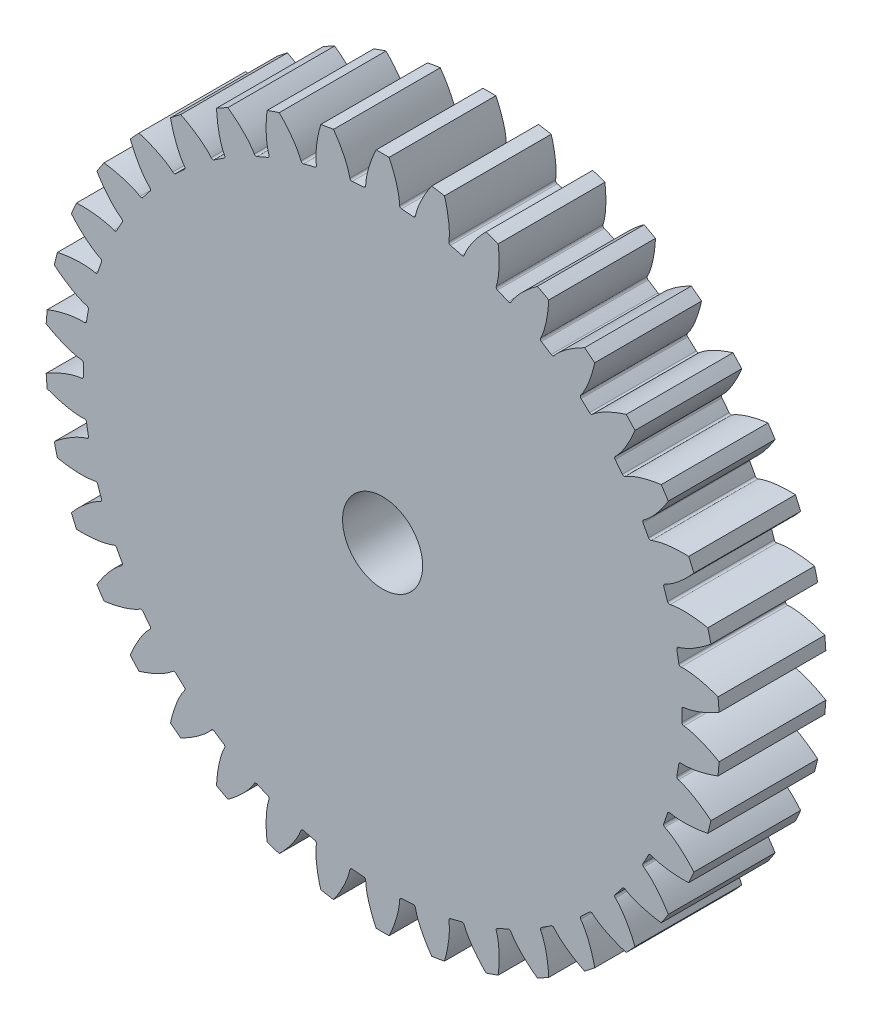
from build123d import *

# Parameters (mm, degrees)
SKETCH4_R                                  = 12.63
ADDENDUM_EXTRUDED_DEPTH                    = 2
F_1_2_TOOTH_CUT_DEPTH                      = 2
ROOTS_FILLET_R                             = 0.07875
CIRCULAR_PATTERN_OF_TEETH_COUNT            = 38
CIRCULAR_PATTERN_OF_TEETH_COPY_1_DEPTH     = 2
CIRCULAR_PATTERN_OF_TEETH_COPY_2_DEPTH     = 2
CIRCULAR_PATTERN_OF_TEETH_COPY_3_DEPTH     = 2
CIRCULAR_PATTERN_OF_TEETH_COPY_4_DEPTH     = 2
CIRCULAR_PATTERN_OF_TEETH_COPY_5_DEPTH     = 2
CIRCULAR_PATTERN_OF_TEETH_COPY_6_DEPTH     = 2
CIRCULAR_PATTERN_OF_TEETH_COPY_7_DEPTH     = 2
CIRCULAR_PATTERN_OF_TEETH_COPY_8_DEPTH     = 2
CIRCULAR_PATTERN_OF_TEETH_COPY_9_DEPTH     = 2
CIRCULAR_PATTERN_OF_TEETH_COPY_10_DEPTH    = 2
CIRCULAR_PATTERN_OF_TEETH_COPY_11_DEPTH    = 2
CIRCULAR_PATTERN_OF_TEETH_COPY_12_DEPTH    = 2
CIRCULAR_PATTERN_OF_TEETH_COPY_13_DEPTH    = 2
CIRCULAR_PATTERN_OF_TEETH_COPY_14_DEPTH    = 2
CIRCULAR_PATTERN_OF_TEETH_COPY_15_DEPTH    = 2
CIRCULAR_PATTERN_OF_TEETH_COPY_16_DEPTH    = 2
CIRCULAR_PATTERN_OF_TEETH_COPY_17_DEPTH    = 2
CIRCULAR_PATTERN_OF_TEETH_COPY_18_DEPTH    = 2
CIRCULAR_PATTERN_OF_TEETH_COPY_19_DEPTH    = 2
CIRCULAR_PATTERN_OF_TEETH_COPY_20_DEPTH    = 2
CIRCULAR_PATTERN_OF_TEETH_COPY_21_DEPTH    = 2
CIRCULAR_PATTERN_OF_TEETH_COPY_22_DEPTH    = 2
CIRCULAR_PATTERN_OF_TEETH_COPY_23_DEPTH    = 2
CIRCULAR_PATTERN_OF_TEETH_COPY_24_DEPTH    = 2
CIRCULAR_PATTERN_OF_TEETH_COPY_25_DEPTH    = 2
CIRCULAR_PATTERN_OF_TEETH_COPY_26_DEPTH    = 2
CIRCULAR_PATTERN_OF_TEETH_COPY_27_DEPTH    = 2
CIRCULAR_PATTERN_OF_TEETH_COPY_28_DEPTH    = 2
CIRCULAR_PATTERN_OF_TEETH_COPY_29_DEPTH    = 2
CIRCULAR_PATTERN_OF_TEETH_COPY_30_DEPTH    = 2
CIRCULAR_PATTERN_OF_TEETH_COPY_31_DEPTH    = 2
CIRCULAR_PATTERN_OF_TEETH_COPY_32_DEPTH    = 2
CIRCULAR_PATTERN_OF_TEETH_COPY_33_DEPTH    = 2
CIRCULAR_PATTERN_OF_TEETH_COPY_34_DEPTH    = 2
CIRCULAR_PATTERN_OF_TEETH_COPY_35_DEPTH    = 2
CIRCULAR_PATTERN_OF_TEETH_COPY_36_DEPTH    = 2
CIRCULAR_PATTERN_OF_TEETH_COPY_37_DEPTH    = 2
ROOTS_FILLET_OF_CIRCULAR_PATTERN_OF_TEET_R = 0.07875
SKETCH13_R                                 = 1.5
CUT_EXTRUDE8_DEPTH                         = 5.0000001


with BuildPart() as part:
    # Sketch4 → Addendum Extruded (new body, symmetric)
    with BuildSketch(Plane.XY):
        Circle(SKETCH4_R)
    extrude(amount=ADDENDUM_EXTRUDED_DEPTH, both=True)

    # Tooth Profile Curve → 1/2 Tooth Cut (cut, symmetric)
    with BuildSketch(Plane.XY):
        with BuildLine():
            add(Edge.make_bspline(
                [(11.272382673, 0.297638681), (11.280712139, 0.298026289), (11.304042203, 0.299658744), (11.347996675, 0.304896676), (11.419345135, 0.316484969), (11.50958792, 0.335699387), (11.625240829, 0.365603979), (11.760010131, 0.407299931), (11.906314767, 0.459829591), (12.063279961, 0.524126508), (12.217722367, 0.594521582), (12.369598127, 0.670479351), (12.48469603, 0.732804764), (12.561604801, 0.776660568), (12.601386277, 0.799916958), (12.604526443, 0.801756283)],
                knots=[0, 0, 0, 0, 0, 0.005376748, 0.015083688, 0.02853182, 0.046610139, 0.064854849, 0.092110525, 0.119476175, 0.146842495, 0.174208853, 0.201574955, 0.228941013, 0.231287576, 0.231287576, 0.231287576, 0.231287576, 0.231287576], degree=4))
            Line((11.272382673, 0.297638681), (11.208593456, 0.295954376))
            ThreePointArc((11.208593456, 0.295954376), (11.211523321, 0.147990079), (11.2125, 0))
            Line((11.2125, 0), (12.63, 0))
            ThreePointArc((12.63, 0), (12.623630004, 0.401080428), (12.604526443, 0.801756283))
        make_face()
    f_1_2_tooth_cut = extrude(amount=F_1_2_TOOTH_CUT_DEPTH, both=True, mode=Mode.SUBTRACT)

    # Mirror Tooth Cut: 1/2 Tooth Cut across plane
    add(f_1_2_tooth_cut.mirror(Plane.ZX), mode=Mode.SUBTRACT)

    # Roots Fillet
    roots_fillet_edges = [part.edges().sort_by_distance(p)[0] for p in [
        (11.208593456, -0.295954376, 0),
        (11.208593456, 0.295954376, 0),
    ]]
    fillet(roots_fillet_edges, radius=ROOTS_FILLET_R)

    # Circular Pattern of Teeth: 1/2 Tooth Cut ×38 about axis
    circular_pattern_of_teeth_axis = Axis((0, 0, -2), (0, 0, 1))
    for i in range(1, CIRCULAR_PATTERN_OF_TEETH_COUNT):
        add(f_1_2_tooth_cut.rotate(circular_pattern_of_teeth_axis, i * 360 / CIRCULAR_PATTERN_OF_TEETH_COUNT), mode=Mode.SUBTRACT)

    # Circular Pattern of Teeth copy 1 sketch → Circular Pattern of Teeth copy 1 (cut, symmetric)
    with BuildSketch(Plane(origin=(0, 0, 0), x_dir=(0.986361303, 0.16459459, 0), z_dir=(0, 0, 1))):
        with BuildLine():
            add(Edge.make_bspline(
                [(11.272382673, -0.297638681), (11.280712139, -0.298026289), (11.304042203, -0.299658744), (11.347996675, -0.304896676), (11.419345135, -0.316484969), (11.50958792, -0.335699387), (11.625240829, -0.365603979), (11.760010131, -0.407299931), (11.906314767, -0.459829591), (12.063279961, -0.524126508), (12.217722367, -0.594521582), (12.369598127, -0.670479351), (12.48469603, -0.732804764), (12.561604801, -0.776660568), (12.601386277, -0.799916958), (12.604526443, -0.801756283)],
                knots=[0, 0, 0, 0, 0, 0.005376748, 0.015083688, 0.02853182, 0.046610139, 0.064854849, 0.092110525, 0.119476175, 0.146842495, 0.174208853, 0.201574955, 0.228941013, 0.231287576, 0.231287576, 0.231287576, 0.231287576, 0.231287576], degree=4))
            Line((11.272382673, -0.297638681), (11.208593456, -0.295954376))
            ThreePointArc((11.208593456, -0.295954376), (11.211523321, -0.147990079), (11.2125, 0))
            Line((11.2125, 0), (12.63, 0))
            ThreePointArc((12.63, 0), (12.623630004, -0.401080428), (12.604526443, -0.801756283))
        make_face()
    extrude(amount=CIRCULAR_PATTERN_OF_TEETH_COPY_1_DEPTH, both=True, mode=Mode.SUBTRACT)

    # Circular Pattern of Teeth copy 2 sketch → Circular Pattern of Teeth copy 2 (cut, symmetric)
    with BuildSketch(Plane(origin=(0, 0, 0), x_dir=(0.945817242, 0.324699469, 0), z_dir=(0, 0, 1))):
        with BuildLine():
            add(Edge.make_bspline(
                [(11.272382673, -0.297638681), (11.280712139, -0.298026289), (11.304042203, -0.299658744), (11.347996675, -0.304896676), (11.419345135, -0.316484969), (11.50958792, -0.335699387), (11.625240829, -0.365603979), (11.760010131, -0.407299931), (11.906314767, -0.459829591), (12.063279961, -0.524126508), (12.217722367, -0.594521582), (12.369598127, -0.670479351), (12.48469603, -0.732804764), (12.561604801, -0.776660568), (12.601386277, -0.799916958), (12.604526443, -0.801756283)],
                knots=[0, 0, 0, 0, 0, 0.005376748, 0.015083688, 0.02853182, 0.046610139, 0.064854849, 0.092110525, 0.119476175, 0.146842495, 0.174208853, 0.201574955, 0.228941013, 0.231287576, 0.231287576, 0.231287576, 0.231287576, 0.231287576], degree=4))
            Line((11.272382673, -0.297638681), (11.208593456, -0.295954376))
            ThreePointArc((11.208593456, -0.295954376), (11.211523321, -0.147990079), (11.2125, 0))
            Line((11.2125, 0), (12.63, 0))
            ThreePointArc((12.63, 0), (12.623630004, -0.401080428), (12.604526443, -0.801756283))
        make_face()
    extrude(amount=CIRCULAR_PATTERN_OF_TEETH_COPY_2_DEPTH, both=True, mode=Mode.SUBTRACT)

    # Circular Pattern of Teeth copy 3 sketch → Circular Pattern of Teeth copy 3 (cut, symmetric)
    with BuildSketch(Plane(origin=(0, 0, 0), x_dir=(0.879473751, 0.475947393, 0), z_dir=(0, 0, 1))):
        with BuildLine():
            add(Edge.make_bspline(
                [(11.272382673, -0.297638681), (11.280712139, -0.298026289), (11.304042203, -0.299658744), (11.347996675, -0.304896676), (11.419345135, -0.316484969), (11.50958792, -0.335699387), (11.625240829, -0.365603979), (11.760010131, -0.407299931), (11.906314767, -0.459829591), (12.063279961, -0.524126508), (12.217722367, -0.594521582), (12.369598127, -0.670479351), (12.48469603, -0.732804764), (12.561604801, -0.776660568), (12.601386277, -0.799916958), (12.604526443, -0.801756283)],
                knots=[0, 0, 0, 0, 0, 0.005376748, 0.015083688, 0.02853182, 0.046610139, 0.064854849, 0.092110525, 0.119476175, 0.146842495, 0.174208853, 0.201574955, 0.228941013, 0.231287576, 0.231287576, 0.231287576, 0.231287576, 0.231287576], degree=4))
            Line((11.272382673, -0.297638681), (11.208593456, -0.295954376))
            ThreePointArc((11.208593456, -0.295954376), (11.211523321, -0.147990079), (11.2125, 0))
            Line((11.2125, 0), (12.63, 0))
            ThreePointArc((12.63, 0), (12.623630004, -0.401080428), (12.604526443, -0.801756283))
        make_face()
    extrude(amount=CIRCULAR_PATTERN_OF_TEETH_COPY_3_DEPTH, both=True, mode=Mode.SUBTRACT)

    # Circular Pattern of Teeth copy 4 sketch → Circular Pattern of Teeth copy 4 (cut, symmetric)
    with BuildSketch(Plane(origin=(0, 0, 0), x_dir=(0.789140509, 0.614212713, 0), z_dir=(0, 0, 1))):
        with BuildLine():
            add(Edge.make_bspline(
                [(11.272382673, -0.297638681), (11.280712139, -0.298026289), (11.304042203, -0.299658744), (11.347996675, -0.304896676), (11.419345135, -0.316484969), (11.50958792, -0.335699387), (11.625240829, -0.365603979), (11.760010131, -0.407299931), (11.906314767, -0.459829591), (12.063279961, -0.524126508), (12.217722367, -0.594521582), (12.369598127, -0.670479351), (12.48469603, -0.732804764), (12.561604801, -0.776660568), (12.601386277, -0.799916958), (12.604526443, -0.801756283)],
                knots=[0, 0, 0, 0, 0, 0.005376748, 0.015083688, 0.02853182, 0.046610139, 0.064854849, 0.092110525, 0.119476175, 0.146842495, 0.174208853, 0.201574955, 0.228941013, 0.231287576, 0.231287576, 0.231287576, 0.231287576, 0.231287576], degree=4))
            Line((11.272382673, -0.297638681), (11.208593456, -0.295954376))
            ThreePointArc((11.208593456, -0.295954376), (11.211523321, -0.147990079), (11.2125, 0))
            Line((11.2125, 0), (12.63, 0))
            ThreePointArc((12.63, 0), (12.623630004, -0.401080428), (12.604526443, -0.801756283))
        make_face()
    extrude(amount=CIRCULAR_PATTERN_OF_TEETH_COPY_4_DEPTH, both=True, mode=Mode.SUBTRACT)

    # Circular Pattern of Teeth copy 5 sketch → Circular Pattern of Teeth copy 5 (cut, symmetric)
    with BuildSketch(Plane(origin=(0, 0, 0), x_dir=(0.677281572, 0.735723911, 0), z_dir=(0, 0, 1))):
        with BuildLine():
            add(Edge.make_bspline(
                [(11.272382673, -0.297638681), (11.280712139, -0.298026289), (11.304042203, -0.299658744), (11.347996675, -0.304896676), (11.419345135, -0.316484969), (11.50958792, -0.335699387), (11.625240829, -0.365603979), (11.760010131, -0.407299931), (11.906314767, -0.459829591), (12.063279961, -0.524126508), (12.217722367, -0.594521582), (12.369598127, -0.670479351), (12.48469603, -0.732804764), (12.561604801, -0.776660568), (12.601386277, -0.799916958), (12.604526443, -0.801756283)],
                knots=[0, 0, 0, 0, 0, 0.005376748, 0.015083688, 0.02853182, 0.046610139, 0.064854849, 0.092110525, 0.119476175, 0.146842495, 0.174208853, 0.201574955, 0.228941013, 0.231287576, 0.231287576, 0.231287576, 0.231287576, 0.231287576], degree=4))
            Line((11.272382673, -0.297638681), (11.208593456, -0.295954376))
            ThreePointArc((11.208593456, -0.295954376), (11.211523321, -0.147990079), (11.2125, 0))
            Line((11.2125, 0), (12.63, 0))
            ThreePointArc((12.63, 0), (12.623630004, -0.401080428), (12.604526443, -0.801756283))
        make_face()
    extrude(amount=CIRCULAR_PATTERN_OF_TEETH_COPY_5_DEPTH, both=True, mode=Mode.SUBTRACT)

    # Circular Pattern of Teeth copy 6 sketch → Circular Pattern of Teeth copy 6 (cut, symmetric)
    with BuildSketch(Plane(origin=(0, 0, 0), x_dir=(0.546948158, 0.837166478, 0), z_dir=(0, 0, 1))):
        with BuildLine():
            add(Edge.make_bspline(
                [(11.272382673, -0.297638681), (11.280712139, -0.298026289), (11.304042203, -0.299658744), (11.347996675, -0.304896676), (11.419345135, -0.316484969), (11.50958792, -0.335699387), (11.625240829, -0.365603979), (11.760010131, -0.407299931), (11.906314767, -0.459829591), (12.063279961, -0.524126508), (12.217722367, -0.594521582), (12.369598127, -0.670479351), (12.48469603, -0.732804764), (12.561604801, -0.776660568), (12.601386277, -0.799916958), (12.604526443, -0.801756283)],
                knots=[0, 0, 0, 0, 0, 0.005376748, 0.015083688, 0.02853182, 0.046610139, 0.064854849, 0.092110525, 0.119476175, 0.146842495, 0.174208853, 0.201574955, 0.228941013, 0.231287576, 0.231287576, 0.231287576, 0.231287576, 0.231287576], degree=4))
            Line((11.272382673, -0.297638681), (11.208593456, -0.295954376))
            ThreePointArc((11.208593456, -0.295954376), (11.211523321, -0.147990079), (11.2125, 0))
            Line((11.2125, 0), (12.63, 0))
            ThreePointArc((12.63, 0), (12.623630004, -0.401080428), (12.604526443, -0.801756283))
        make_face()
    extrude(amount=CIRCULAR_PATTERN_OF_TEETH_COPY_6_DEPTH, both=True, mode=Mode.SUBTRACT)

    # Circular Pattern of Teeth copy 7 sketch → Circular Pattern of Teeth copy 7 (cut, symmetric)
    with BuildSketch(Plane(origin=(0, 0, 0), x_dir=(0.401695425, 0.915773327, 0), z_dir=(0, 0, 1))):
        with BuildLine():
            add(Edge.make_bspline(
                [(11.272382673, -0.297638681), (11.280712139, -0.298026289), (11.304042203, -0.299658744), (11.347996675, -0.304896676), (11.419345135, -0.316484969), (11.50958792, -0.335699387), (11.625240829, -0.365603979), (11.760010131, -0.407299931), (11.906314767, -0.459829591), (12.063279961, -0.524126508), (12.217722367, -0.594521582), (12.369598127, -0.670479351), (12.48469603, -0.732804764), (12.561604801, -0.776660568), (12.601386277, -0.799916958), (12.604526443, -0.801756283)],
                knots=[0, 0, 0, 0, 0, 0.005376748, 0.015083688, 0.02853182, 0.046610139, 0.064854849, 0.092110525, 0.119476175, 0.146842495, 0.174208853, 0.201574955, 0.228941013, 0.231287576, 0.231287576, 0.231287576, 0.231287576, 0.231287576], degree=4))
            Line((11.272382673, -0.297638681), (11.208593456, -0.295954376))
            ThreePointArc((11.208593456, -0.295954376), (11.211523321, -0.147990079), (11.2125, 0))
            Line((11.2125, 0), (12.63, 0))
            ThreePointArc((12.63, 0), (12.623630004, -0.401080428), (12.604526443, -0.801756283))
        make_face()
    extrude(amount=CIRCULAR_PATTERN_OF_TEETH_COPY_7_DEPTH, both=True, mode=Mode.SUBTRACT)

    # Circular Pattern of Teeth copy 8 sketch → Circular Pattern of Teeth copy 8 (cut, symmetric)
    with BuildSketch(Plane(origin=(0, 0, 0), x_dir=(0.245485487, 0.969400266, 0), z_dir=(0, 0, 1))):
        with BuildLine():
            add(Edge.make_bspline(
                [(11.272382673, -0.297638681), (11.280712139, -0.298026289), (11.304042203, -0.299658744), (11.347996675, -0.304896676), (11.419345135, -0.316484969), (11.50958792, -0.335699387), (11.625240829, -0.365603979), (11.760010131, -0.407299931), (11.906314767, -0.459829591), (12.063279961, -0.524126508), (12.217722367, -0.594521582), (12.369598127, -0.670479351), (12.48469603, -0.732804764), (12.561604801, -0.776660568), (12.601386277, -0.799916958), (12.604526443, -0.801756283)],
                knots=[0, 0, 0, 0, 0, 0.005376748, 0.015083688, 0.02853182, 0.046610139, 0.064854849, 0.092110525, 0.119476175, 0.146842495, 0.174208853, 0.201574955, 0.228941013, 0.231287576, 0.231287576, 0.231287576, 0.231287576, 0.231287576], degree=4))
            Line((11.272382673, -0.297638681), (11.208593456, -0.295954376))
            ThreePointArc((11.208593456, -0.295954376), (11.211523321, -0.147990079), (11.2125, 0))
            Line((11.2125, 0), (12.63, 0))
            ThreePointArc((12.63, 0), (12.623630004, -0.401080428), (12.604526443, -0.801756283))
        make_face()
    extrude(amount=CIRCULAR_PATTERN_OF_TEETH_COPY_8_DEPTH, both=True, mode=Mode.SUBTRACT)

    # Circular Pattern of Teeth copy 9 sketch → Circular Pattern of Teeth copy 9 (cut, symmetric)
    with BuildSketch(Plane(origin=(0, 0, 0), x_dir=(0.082579345, 0.996584493, 0), z_dir=(0, 0, 1))):
        with BuildLine():
            add(Edge.make_bspline(
                [(11.272382673, -0.297638681), (11.280712139, -0.298026289), (11.304042203, -0.299658744), (11.347996675, -0.304896676), (11.419345135, -0.316484969), (11.50958792, -0.335699387), (11.625240829, -0.365603979), (11.760010131, -0.407299931), (11.906314767, -0.459829591), (12.063279961, -0.524126508), (12.217722367, -0.594521582), (12.369598127, -0.670479351), (12.48469603, -0.732804764), (12.561604801, -0.776660568), (12.601386277, -0.799916958), (12.604526443, -0.801756283)],
                knots=[0, 0, 0, 0, 0, 0.005376748, 0.015083688, 0.02853182, 0.046610139, 0.064854849, 0.092110525, 0.119476175, 0.146842495, 0.174208853, 0.201574955, 0.228941013, 0.231287576, 0.231287576, 0.231287576, 0.231287576, 0.231287576], degree=4))
            Line((11.272382673, -0.297638681), (11.208593456, -0.295954376))
            ThreePointArc((11.208593456, -0.295954376), (11.211523321, -0.147990079), (11.2125, 0))
            Line((11.2125, 0), (12.63, 0))
            ThreePointArc((12.63, 0), (12.623630004, -0.401080428), (12.604526443, -0.801756283))
        make_face()
    extrude(amount=CIRCULAR_PATTERN_OF_TEETH_COPY_9_DEPTH, both=True, mode=Mode.SUBTRACT)

    # Circular Pattern of Teeth copy 10 sketch → Circular Pattern of Teeth copy 10 (cut, symmetric)
    with BuildSketch(Plane(origin=(0, 0, 0), x_dir=(-0.082579345, 0.996584493, 0), z_dir=(0, 0, 1))):
        with BuildLine():
            add(Edge.make_bspline(
                [(11.272382673, -0.297638681), (11.280712139, -0.298026289), (11.304042203, -0.299658744), (11.347996675, -0.304896676), (11.419345135, -0.316484969), (11.50958792, -0.335699387), (11.625240829, -0.365603979), (11.760010131, -0.407299931), (11.906314767, -0.459829591), (12.063279961, -0.524126508), (12.217722367, -0.594521582), (12.369598127, -0.670479351), (12.48469603, -0.732804764), (12.561604801, -0.776660568), (12.601386277, -0.799916958), (12.604526443, -0.801756283)],
                knots=[0, 0, 0, 0, 0, 0.005376748, 0.015083688, 0.02853182, 0.046610139, 0.064854849, 0.092110525, 0.119476175, 0.146842495, 0.174208853, 0.201574955, 0.228941013, 0.231287576, 0.231287576, 0.231287576, 0.231287576, 0.231287576], degree=4))
            Line((11.272382673, -0.297638681), (11.208593456, -0.295954376))
            ThreePointArc((11.208593456, -0.295954376), (11.211523321, -0.147990079), (11.2125, 0))
            Line((11.2125, 0), (12.63, 0))
            ThreePointArc((12.63, 0), (12.623630004, -0.401080428), (12.604526443, -0.801756283))
        make_face()
    extrude(amount=CIRCULAR_PATTERN_OF_TEETH_COPY_10_DEPTH, both=True, mode=Mode.SUBTRACT)

    # Circular Pattern of Teeth copy 11 sketch → Circular Pattern of Teeth copy 11 (cut, symmetric)
    with BuildSketch(Plane(origin=(0, 0, 0), x_dir=(-0.245485487, 0.969400266, 0), z_dir=(0, 0, 1))):
        with BuildLine():
            add(Edge.make_bspline(
                [(11.272382673, -0.297638681), (11.280712139, -0.298026289), (11.304042203, -0.299658744), (11.347996675, -0.304896676), (11.419345135, -0.316484969), (11.50958792, -0.335699387), (11.625240829, -0.365603979), (11.760010131, -0.407299931), (11.906314767, -0.459829591), (12.063279961, -0.524126508), (12.217722367, -0.594521582), (12.369598127, -0.670479351), (12.48469603, -0.732804764), (12.561604801, -0.776660568), (12.601386277, -0.799916958), (12.604526443, -0.801756283)],
                knots=[0, 0, 0, 0, 0, 0.005376748, 0.015083688, 0.02853182, 0.046610139, 0.064854849, 0.092110525, 0.119476175, 0.146842495, 0.174208853, 0.201574955, 0.228941013, 0.231287576, 0.231287576, 0.231287576, 0.231287576, 0.231287576], degree=4))
            Line((11.272382673, -0.297638681), (11.208593456, -0.295954376))
            ThreePointArc((11.208593456, -0.295954376), (11.211523321, -0.147990079), (11.2125, 0))
            Line((11.2125, 0), (12.63, 0))
            ThreePointArc((12.63, 0), (12.623630004, -0.401080428), (12.604526443, -0.801756283))
        make_face()
    extrude(amount=CIRCULAR_PATTERN_OF_TEETH_COPY_11_DEPTH, both=True, mode=Mode.SUBTRACT)

    # Circular Pattern of Teeth copy 12 sketch → Circular Pattern of Teeth copy 12 (cut, symmetric)
    with BuildSketch(Plane(origin=(0, 0, 0), x_dir=(-0.401695425, 0.915773327, 0), z_dir=(0, 0, 1))):
        with BuildLine():
            add(Edge.make_bspline(
                [(11.272382673, -0.297638681), (11.280712139, -0.298026289), (11.304042203, -0.299658744), (11.347996675, -0.304896676), (11.419345135, -0.316484969), (11.50958792, -0.335699387), (11.625240829, -0.365603979), (11.760010131, -0.407299931), (11.906314767, -0.459829591), (12.063279961, -0.524126508), (12.217722367, -0.594521582), (12.369598127, -0.670479351), (12.48469603, -0.732804764), (12.561604801, -0.776660568), (12.601386277, -0.799916958), (12.604526443, -0.801756283)],
                knots=[0, 0, 0, 0, 0, 0.005376748, 0.015083688, 0.02853182, 0.046610139, 0.064854849, 0.092110525, 0.119476175, 0.146842495, 0.174208853, 0.201574955, 0.228941013, 0.231287576, 0.231287576, 0.231287576, 0.231287576, 0.231287576], degree=4))
            Line((11.272382673, -0.297638681), (11.208593456, -0.295954376))
            ThreePointArc((11.208593456, -0.295954376), (11.211523321, -0.147990079), (11.2125, 0))
            Line((11.2125, 0), (12.63, 0))
            ThreePointArc((12.63, 0), (12.623630004, -0.401080428), (12.604526443, -0.801756283))
        make_face()
    extrude(amount=CIRCULAR_PATTERN_OF_TEETH_COPY_12_DEPTH, both=True, mode=Mode.SUBTRACT)

    # Circular Pattern of Teeth copy 13 sketch → Circular Pattern of Teeth copy 13 (cut, symmetric)
    with BuildSketch(Plane(origin=(0, 0, 0), x_dir=(-0.546948158, 0.837166478, 0), z_dir=(0, 0, 1))):
        with BuildLine():
            add(Edge.make_bspline(
                [(11.272382673, -0.297638681), (11.280712139, -0.298026289), (11.304042203, -0.299658744), (11.347996675, -0.304896676), (11.419345135, -0.316484969), (11.50958792, -0.335699387), (11.625240829, -0.365603979), (11.760010131, -0.407299931), (11.906314767, -0.459829591), (12.063279961, -0.524126508), (12.217722367, -0.594521582), (12.369598127, -0.670479351), (12.48469603, -0.732804764), (12.561604801, -0.776660568), (12.601386277, -0.799916958), (12.604526443, -0.801756283)],
                knots=[0, 0, 0, 0, 0, 0.005376748, 0.015083688, 0.02853182, 0.046610139, 0.064854849, 0.092110525, 0.119476175, 0.146842495, 0.174208853, 0.201574955, 0.228941013, 0.231287576, 0.231287576, 0.231287576, 0.231287576, 0.231287576], degree=4))
            Line((11.272382673, -0.297638681), (11.208593456, -0.295954376))
            ThreePointArc((11.208593456, -0.295954376), (11.211523321, -0.147990079), (11.2125, 0))
            Line((11.2125, 0), (12.63, 0))
            ThreePointArc((12.63, 0), (12.623630004, -0.401080428), (12.604526443, -0.801756283))
        make_face()
    extrude(amount=CIRCULAR_PATTERN_OF_TEETH_COPY_13_DEPTH, both=True, mode=Mode.SUBTRACT)

    # Circular Pattern of Teeth copy 14 sketch → Circular Pattern of Teeth copy 14 (cut, symmetric)
    with BuildSketch(Plane(origin=(0, 0, 0), x_dir=(-0.677281572, 0.735723911, 0), z_dir=(0, 0, 1))):
        with BuildLine():
            add(Edge.make_bspline(
                [(11.272382673, -0.297638681), (11.280712139, -0.298026289), (11.304042203, -0.299658744), (11.347996675, -0.304896676), (11.419345135, -0.316484969), (11.50958792, -0.335699387), (11.625240829, -0.365603979), (11.760010131, -0.407299931), (11.906314767, -0.459829591), (12.063279961, -0.524126508), (12.217722367, -0.594521582), (12.369598127, -0.670479351), (12.48469603, -0.732804764), (12.561604801, -0.776660568), (12.601386277, -0.799916958), (12.604526443, -0.801756283)],
                knots=[0, 0, 0, 0, 0, 0.005376748, 0.015083688, 0.02853182, 0.046610139, 0.064854849, 0.092110525, 0.119476175, 0.146842495, 0.174208853, 0.201574955, 0.228941013, 0.231287576, 0.231287576, 0.231287576, 0.231287576, 0.231287576], degree=4))
            Line((11.272382673, -0.297638681), (11.208593456, -0.295954376))
            ThreePointArc((11.208593456, -0.295954376), (11.211523321, -0.147990079), (11.2125, 0))
            Line((11.2125, 0), (12.63, 0))
            ThreePointArc((12.63, 0), (12.623630004, -0.401080428), (12.604526443, -0.801756283))
        make_face()
    extrude(amount=CIRCULAR_PATTERN_OF_TEETH_COPY_14_DEPTH, both=True, mode=Mode.SUBTRACT)

    # Circular Pattern of Teeth copy 15 sketch → Circular Pattern of Teeth copy 15 (cut, symmetric)
    with BuildSketch(Plane(origin=(0, 0, 0), x_dir=(-0.789140509, 0.614212713, 0), z_dir=(0, 0, 1))):
        with BuildLine():
            add(Edge.make_bspline(
                [(11.272382673, -0.297638681), (11.280712139, -0.298026289), (11.304042203, -0.299658744), (11.347996675, -0.304896676), (11.419345135, -0.316484969), (11.50958792, -0.335699387), (11.625240829, -0.365603979), (11.760010131, -0.407299931), (11.906314767, -0.459829591), (12.063279961, -0.524126508), (12.217722367, -0.594521582), (12.369598127, -0.670479351), (12.48469603, -0.732804764), (12.561604801, -0.776660568), (12.601386277, -0.799916958), (12.604526443, -0.801756283)],
                knots=[0, 0, 0, 0, 0, 0.005376748, 0.015083688, 0.02853182, 0.046610139, 0.064854849, 0.092110525, 0.119476175, 0.146842495, 0.174208853, 0.201574955, 0.228941013, 0.231287576, 0.231287576, 0.231287576, 0.231287576, 0.231287576], degree=4))
            Line((11.272382673, -0.297638681), (11.208593456, -0.295954376))
            ThreePointArc((11.208593456, -0.295954376), (11.211523321, -0.147990079), (11.2125, 0))
            Line((11.2125, 0), (12.63, 0))
            ThreePointArc((12.63, 0), (12.623630004, -0.401080428), (12.604526443, -0.801756283))
        make_face()
    extrude(amount=CIRCULAR_PATTERN_OF_TEETH_COPY_15_DEPTH, both=True, mode=Mode.SUBTRACT)

    # Circular Pattern of Teeth copy 16 sketch → Circular Pattern of Teeth copy 16 (cut, symmetric)
    with BuildSketch(Plane(origin=(0, 0, 0), x_dir=(-0.879473751, 0.475947393, 0), z_dir=(0, 0, 1))):
        with BuildLine():
            add(Edge.make_bspline(
                [(11.272382673, -0.297638681), (11.280712139, -0.298026289), (11.304042203, -0.299658744), (11.347996675, -0.304896676), (11.419345135, -0.316484969), (11.50958792, -0.335699387), (11.625240829, -0.365603979), (11.760010131, -0.407299931), (11.906314767, -0.459829591), (12.063279961, -0.524126508), (12.217722367, -0.594521582), (12.369598127, -0.670479351), (12.48469603, -0.732804764), (12.561604801, -0.776660568), (12.601386277, -0.799916958), (12.604526443, -0.801756283)],
                knots=[0, 0, 0, 0, 0, 0.005376748, 0.015083688, 0.02853182, 0.046610139, 0.064854849, 0.092110525, 0.119476175, 0.146842495, 0.174208853, 0.201574955, 0.228941013, 0.231287576, 0.231287576, 0.231287576, 0.231287576, 0.231287576], degree=4))
            Line((11.272382673, -0.297638681), (11.208593456, -0.295954376))
            ThreePointArc((11.208593456, -0.295954376), (11.211523321, -0.147990079), (11.2125, 0))
            Line((11.2125, 0), (12.63, 0))
            ThreePointArc((12.63, 0), (12.623630004, -0.401080428), (12.604526443, -0.801756283))
        make_face()
    extrude(amount=CIRCULAR_PATTERN_OF_TEETH_COPY_16_DEPTH, both=True, mode=Mode.SUBTRACT)

    # Circular Pattern of Teeth copy 17 sketch → Circular Pattern of Teeth copy 17 (cut, symmetric)
    with BuildSketch(Plane(origin=(0, 0, 0), x_dir=(-0.945817242, 0.324699469, 0), z_dir=(0, 0, 1))):
        with BuildLine():
            add(Edge.make_bspline(
                [(11.272382673, -0.297638681), (11.280712139, -0.298026289), (11.304042203, -0.299658744), (11.347996675, -0.304896676), (11.419345135, -0.316484969), (11.50958792, -0.335699387), (11.625240829, -0.365603979), (11.760010131, -0.407299931), (11.906314767, -0.459829591), (12.063279961, -0.524126508), (12.217722367, -0.594521582), (12.369598127, -0.670479351), (12.48469603, -0.732804764), (12.561604801, -0.776660568), (12.601386277, -0.799916958), (12.604526443, -0.801756283)],
                knots=[0, 0, 0, 0, 0, 0.005376748, 0.015083688, 0.02853182, 0.046610139, 0.064854849, 0.092110525, 0.119476175, 0.146842495, 0.174208853, 0.201574955, 0.228941013, 0.231287576, 0.231287576, 0.231287576, 0.231287576, 0.231287576], degree=4))
            Line((11.272382673, -0.297638681), (11.208593456, -0.295954376))
            ThreePointArc((11.208593456, -0.295954376), (11.211523321, -0.147990079), (11.2125, 0))
            Line((11.2125, 0), (12.63, 0))
            ThreePointArc((12.63, 0), (12.623630004, -0.401080428), (12.604526443, -0.801756283))
        make_face()
    extrude(amount=CIRCULAR_PATTERN_OF_TEETH_COPY_17_DEPTH, both=True, mode=Mode.SUBTRACT)

    # Circular Pattern of Teeth copy 18 sketch → Circular Pattern of Teeth copy 18 (cut, symmetric)
    with BuildSketch(Plane(origin=(0, 0, 0), x_dir=(-0.986361303, 0.16459459, 0), z_dir=(0, 0, 1))):
        with BuildLine():
            add(Edge.make_bspline(
                [(11.272382673, -0.297638681), (11.280712139, -0.298026289), (11.304042203, -0.299658744), (11.347996675, -0.304896676), (11.419345135, -0.316484969), (11.50958792, -0.335699387), (11.625240829, -0.365603979), (11.760010131, -0.407299931), (11.906314767, -0.459829591), (12.063279961, -0.524126508), (12.217722367, -0.594521582), (12.369598127, -0.670479351), (12.48469603, -0.732804764), (12.561604801, -0.776660568), (12.601386277, -0.799916958), (12.604526443, -0.801756283)],
                knots=[0, 0, 0, 0, 0, 0.005376748, 0.015083688, 0.02853182, 0.046610139, 0.064854849, 0.092110525, 0.119476175, 0.146842495, 0.174208853, 0.201574955, 0.228941013, 0.231287576, 0.231287576, 0.231287576, 0.231287576, 0.231287576], degree=4))
            Line((11.272382673, -0.297638681), (11.208593456, -0.295954376))
            ThreePointArc((11.208593456, -0.295954376), (11.211523321, -0.147990079), (11.2125, 0))
            Line((11.2125, 0), (12.63, 0))
            ThreePointArc((12.63, 0), (12.623630004, -0.401080428), (12.604526443, -0.801756283))
        make_face()
    extrude(amount=CIRCULAR_PATTERN_OF_TEETH_COPY_18_DEPTH, both=True, mode=Mode.SUBTRACT)

    # Circular Pattern of Teeth copy 19 sketch → Circular Pattern of Teeth copy 19 (cut, symmetric)
    with BuildSketch(Plane(origin=(0, 0, 0), x_dir=(-1, 0, 0), z_dir=(0, 0, 1))):
        with BuildLine():
            add(Edge.make_bspline(
                [(11.272382673, -0.297638681), (11.280712139, -0.298026289), (11.304042203, -0.299658744), (11.347996675, -0.304896676), (11.419345135, -0.316484969), (11.50958792, -0.335699387), (11.625240829, -0.365603979), (11.760010131, -0.407299931), (11.906314767, -0.459829591), (12.063279961, -0.524126508), (12.217722367, -0.594521582), (12.369598127, -0.670479351), (12.48469603, -0.732804764), (12.561604801, -0.776660568), (12.601386277, -0.799916958), (12.604526443, -0.801756283)],
                knots=[0, 0, 0, 0, 0, 0.005376748, 0.015083688, 0.02853182, 0.046610139, 0.064854849, 0.092110525, 0.119476175, 0.146842495, 0.174208853, 0.201574955, 0.228941013, 0.231287576, 0.231287576, 0.231287576, 0.231287576, 0.231287576], degree=4))
            Line((11.272382673, -0.297638681), (11.208593456, -0.295954376))
            ThreePointArc((11.208593456, -0.295954376), (11.211523321, -0.147990079), (11.2125, 0))
            Line((11.2125, 0), (12.63, 0))
            ThreePointArc((12.63, 0), (12.623630004, -0.401080428), (12.604526443, -0.801756283))
        make_face()
    extrude(amount=CIRCULAR_PATTERN_OF_TEETH_COPY_19_DEPTH, both=True, mode=Mode.SUBTRACT)

    # Circular Pattern of Teeth copy 20 sketch → Circular Pattern of Teeth copy 20 (cut, symmetric)
    with BuildSketch(Plane(origin=(0, 0, 0), x_dir=(-0.986361303, -0.16459459, 0), z_dir=(0, 0, 1))):
        with BuildLine():
            add(Edge.make_bspline(
                [(11.272382673, -0.297638681), (11.280712139, -0.298026289), (11.304042203, -0.299658744), (11.347996675, -0.304896676), (11.419345135, -0.316484969), (11.50958792, -0.335699387), (11.625240829, -0.365603979), (11.760010131, -0.407299931), (11.906314767, -0.459829591), (12.063279961, -0.524126508), (12.217722367, -0.594521582), (12.369598127, -0.670479351), (12.48469603, -0.732804764), (12.561604801, -0.776660568), (12.601386277, -0.799916958), (12.604526443, -0.801756283)],
                knots=[0, 0, 0, 0, 0, 0.005376748, 0.015083688, 0.02853182, 0.046610139, 0.064854849, 0.092110525, 0.119476175, 0.146842495, 0.174208853, 0.201574955, 0.228941013, 0.231287576, 0.231287576, 0.231287576, 0.231287576, 0.231287576], degree=4))
            Line((11.272382673, -0.297638681), (11.208593456, -0.295954376))
            ThreePointArc((11.208593456, -0.295954376), (11.211523321, -0.147990079), (11.2125, 0))
            Line((11.2125, 0), (12.63, 0))
            ThreePointArc((12.63, 0), (12.623630004, -0.401080428), (12.604526443, -0.801756283))
        make_face()
    extrude(amount=CIRCULAR_PATTERN_OF_TEETH_COPY_20_DEPTH, both=True, mode=Mode.SUBTRACT)

    # Circular Pattern of Teeth copy 21 sketch → Circular Pattern of Teeth copy 21 (cut, symmetric)
    with BuildSketch(Plane(origin=(0, 0, 0), x_dir=(-0.945817242, -0.324699469, 0), z_dir=(0, 0, 1))):
        with BuildLine():
            add(Edge.make_bspline(
                [(11.272382673, -0.297638681), (11.280712139, -0.298026289), (11.304042203, -0.299658744), (11.347996675, -0.304896676), (11.419345135, -0.316484969), (11.50958792, -0.335699387), (11.625240829, -0.365603979), (11.760010131, -0.407299931), (11.906314767, -0.459829591), (12.063279961, -0.524126508), (12.217722367, -0.594521582), (12.369598127, -0.670479351), (12.48469603, -0.732804764), (12.561604801, -0.776660568), (12.601386277, -0.799916958), (12.604526443, -0.801756283)],
                knots=[0, 0, 0, 0, 0, 0.005376748, 0.015083688, 0.02853182, 0.046610139, 0.064854849, 0.092110525, 0.119476175, 0.146842495, 0.174208853, 0.201574955, 0.228941013, 0.231287576, 0.231287576, 0.231287576, 0.231287576, 0.231287576], degree=4))
            Line((11.272382673, -0.297638681), (11.208593456, -0.295954376))
            ThreePointArc((11.208593456, -0.295954376), (11.211523321, -0.147990079), (11.2125, 0))
            Line((11.2125, 0), (12.63, 0))
            ThreePointArc((12.63, 0), (12.623630004, -0.401080428), (12.604526443, -0.801756283))
        make_face()
    extrude(amount=CIRCULAR_PATTERN_OF_TEETH_COPY_21_DEPTH, both=True, mode=Mode.SUBTRACT)

    # Circular Pattern of Teeth copy 22 sketch → Circular Pattern of Teeth copy 22 (cut, symmetric)
    with BuildSketch(Plane(origin=(0, 0, 0), x_dir=(-0.879473751, -0.475947393, 0), z_dir=(0, 0, 1))):
        with BuildLine():
            add(Edge.make_bspline(
                [(11.272382673, -0.297638681), (11.280712139, -0.298026289), (11.304042203, -0.299658744), (11.347996675, -0.304896676), (11.419345135, -0.316484969), (11.50958792, -0.335699387), (11.625240829, -0.365603979), (11.760010131, -0.407299931), (11.906314767, -0.459829591), (12.063279961, -0.524126508), (12.217722367, -0.594521582), (12.369598127, -0.670479351), (12.48469603, -0.732804764), (12.561604801, -0.776660568), (12.601386277, -0.799916958), (12.604526443, -0.801756283)],
                knots=[0, 0, 0, 0, 0, 0.005376748, 0.015083688, 0.02853182, 0.046610139, 0.064854849, 0.092110525, 0.119476175, 0.146842495, 0.174208853, 0.201574955, 0.228941013, 0.231287576, 0.231287576, 0.231287576, 0.231287576, 0.231287576], degree=4))
            Line((11.272382673, -0.297638681), (11.208593456, -0.295954376))
            ThreePointArc((11.208593456, -0.295954376), (11.211523321, -0.147990079), (11.2125, 0))
            Line((11.2125, 0), (12.63, 0))
            ThreePointArc((12.63, 0), (12.623630004, -0.401080428), (12.604526443, -0.801756283))
        make_face()
    extrude(amount=CIRCULAR_PATTERN_OF_TEETH_COPY_22_DEPTH, both=True, mode=Mode.SUBTRACT)

    # Circular Pattern of Teeth copy 23 sketch → Circular Pattern of Teeth copy 23 (cut, symmetric)
    with BuildSketch(Plane(origin=(0, 0, 0), x_dir=(-0.789140509, -0.614212713, 0), z_dir=(0, 0, 1))):
        with BuildLine():
            add(Edge.make_bspline(
                [(11.272382673, -0.297638681), (11.280712139, -0.298026289), (11.304042203, -0.299658744), (11.347996675, -0.304896676), (11.419345135, -0.316484969), (11.50958792, -0.335699387), (11.625240829, -0.365603979), (11.760010131, -0.407299931), (11.906314767, -0.459829591), (12.063279961, -0.524126508), (12.217722367, -0.594521582), (12.369598127, -0.670479351), (12.48469603, -0.732804764), (12.561604801, -0.776660568), (12.601386277, -0.799916958), (12.604526443, -0.801756283)],
                knots=[0, 0, 0, 0, 0, 0.005376748, 0.015083688, 0.02853182, 0.046610139, 0.064854849, 0.092110525, 0.119476175, 0.146842495, 0.174208853, 0.201574955, 0.228941013, 0.231287576, 0.231287576, 0.231287576, 0.231287576, 0.231287576], degree=4))
            Line((11.272382673, -0.297638681), (11.208593456, -0.295954376))
            ThreePointArc((11.208593456, -0.295954376), (11.211523321, -0.147990079), (11.2125, 0))
            Line((11.2125, 0), (12.63, 0))
            ThreePointArc((12.63, 0), (12.623630004, -0.401080428), (12.604526443, -0.801756283))
        make_face()
    extrude(amount=CIRCULAR_PATTERN_OF_TEETH_COPY_23_DEPTH, both=True, mode=Mode.SUBTRACT)

    # Circular Pattern of Teeth copy 24 sketch → Circular Pattern of Teeth copy 24 (cut, symmetric)
    with BuildSketch(Plane(origin=(0, 0, 0), x_dir=(-0.677281572, -0.735723911, 0), z_dir=(0, 0, 1))):
        with BuildLine():
            add(Edge.make_bspline(
                [(11.272382673, -0.297638681), (11.280712139, -0.298026289), (11.304042203, -0.299658744), (11.347996675, -0.304896676), (11.419345135, -0.316484969), (11.50958792, -0.335699387), (11.625240829, -0.365603979), (11.760010131, -0.407299931), (11.906314767, -0.459829591), (12.063279961, -0.524126508), (12.217722367, -0.594521582), (12.369598127, -0.670479351), (12.48469603, -0.732804764), (12.561604801, -0.776660568), (12.601386277, -0.799916958), (12.604526443, -0.801756283)],
                knots=[0, 0, 0, 0, 0, 0.005376748, 0.015083688, 0.02853182, 0.046610139, 0.064854849, 0.092110525, 0.119476175, 0.146842495, 0.174208853, 0.201574955, 0.228941013, 0.231287576, 0.231287576, 0.231287576, 0.231287576, 0.231287576], degree=4))
            Line((11.272382673, -0.297638681), (11.208593456, -0.295954376))
            ThreePointArc((11.208593456, -0.295954376), (11.211523321, -0.147990079), (11.2125, 0))
            Line((11.2125, 0), (12.63, 0))
            ThreePointArc((12.63, 0), (12.623630004, -0.401080428), (12.604526443, -0.801756283))
        make_face()
    extrude(amount=CIRCULAR_PATTERN_OF_TEETH_COPY_24_DEPTH, both=True, mode=Mode.SUBTRACT)

    # Circular Pattern of Teeth copy 25 sketch → Circular Pattern of Teeth copy 25 (cut, symmetric)
    with BuildSketch(Plane(origin=(0, 0, 0), x_dir=(-0.546948158, -0.837166478, 0), z_dir=(0, 0, 1))):
        with BuildLine():
            add(Edge.make_bspline(
                [(11.272382673, -0.297638681), (11.280712139, -0.298026289), (11.304042203, -0.299658744), (11.347996675, -0.304896676), (11.419345135, -0.316484969), (11.50958792, -0.335699387), (11.625240829, -0.365603979), (11.760010131, -0.407299931), (11.906314767, -0.459829591), (12.063279961, -0.524126508), (12.217722367, -0.594521582), (12.369598127, -0.670479351), (12.48469603, -0.732804764), (12.561604801, -0.776660568), (12.601386277, -0.799916958), (12.604526443, -0.801756283)],
                knots=[0, 0, 0, 0, 0, 0.005376748, 0.015083688, 0.02853182, 0.046610139, 0.064854849, 0.092110525, 0.119476175, 0.146842495, 0.174208853, 0.201574955, 0.228941013, 0.231287576, 0.231287576, 0.231287576, 0.231287576, 0.231287576], degree=4))
            Line((11.272382673, -0.297638681), (11.208593456, -0.295954376))
            ThreePointArc((11.208593456, -0.295954376), (11.211523321, -0.147990079), (11.2125, 0))
            Line((11.2125, 0), (12.63, 0))
            ThreePointArc((12.63, 0), (12.623630004, -0.401080428), (12.604526443, -0.801756283))
        make_face()
    extrude(amount=CIRCULAR_PATTERN_OF_TEETH_COPY_25_DEPTH, both=True, mode=Mode.SUBTRACT)

    # Circular Pattern of Teeth copy 26 sketch → Circular Pattern of Teeth copy 26 (cut, symmetric)
    with BuildSketch(Plane(origin=(0, 0, 0), x_dir=(-0.401695425, -0.915773327, 0), z_dir=(0, 0, 1))):
        with BuildLine():
            add(Edge.make_bspline(
                [(11.272382673, -0.297638681), (11.280712139, -0.298026289), (11.304042203, -0.299658744), (11.347996675, -0.304896676), (11.419345135, -0.316484969), (11.50958792, -0.335699387), (11.625240829, -0.365603979), (11.760010131, -0.407299931), (11.906314767, -0.459829591), (12.063279961, -0.524126508), (12.217722367, -0.594521582), (12.369598127, -0.670479351), (12.48469603, -0.732804764), (12.561604801, -0.776660568), (12.601386277, -0.799916958), (12.604526443, -0.801756283)],
                knots=[0, 0, 0, 0, 0, 0.005376748, 0.015083688, 0.02853182, 0.046610139, 0.064854849, 0.092110525, 0.119476175, 0.146842495, 0.174208853, 0.201574955, 0.228941013, 0.231287576, 0.231287576, 0.231287576, 0.231287576, 0.231287576], degree=4))
            Line((11.272382673, -0.297638681), (11.208593456, -0.295954376))
            ThreePointArc((11.208593456, -0.295954376), (11.211523321, -0.147990079), (11.2125, 0))
            Line((11.2125, 0), (12.63, 0))
            ThreePointArc((12.63, 0), (12.623630004, -0.401080428), (12.604526443, -0.801756283))
        make_face()
    extrude(amount=CIRCULAR_PATTERN_OF_TEETH_COPY_26_DEPTH, both=True, mode=Mode.SUBTRACT)

    # Circular Pattern of Teeth copy 27 sketch → Circular Pattern of Teeth copy 27 (cut, symmetric)
    with BuildSketch(Plane(origin=(0, 0, 0), x_dir=(-0.245485487, -0.969400266, 0), z_dir=(0, 0, 1))):
        with BuildLine():
            add(Edge.make_bspline(
                [(11.272382673, -0.297638681), (11.280712139, -0.298026289), (11.304042203, -0.299658744), (11.347996675, -0.304896676), (11.419345135, -0.316484969), (11.50958792, -0.335699387), (11.625240829, -0.365603979), (11.760010131, -0.407299931), (11.906314767, -0.459829591), (12.063279961, -0.524126508), (12.217722367, -0.594521582), (12.369598127, -0.670479351), (12.48469603, -0.732804764), (12.561604801, -0.776660568), (12.601386277, -0.799916958), (12.604526443, -0.801756283)],
                knots=[0, 0, 0, 0, 0, 0.005376748, 0.015083688, 0.02853182, 0.046610139, 0.064854849, 0.092110525, 0.119476175, 0.146842495, 0.174208853, 0.201574955, 0.228941013, 0.231287576, 0.231287576, 0.231287576, 0.231287576, 0.231287576], degree=4))
            Line((11.272382673, -0.297638681), (11.208593456, -0.295954376))
            ThreePointArc((11.208593456, -0.295954376), (11.211523321, -0.147990079), (11.2125, 0))
            Line((11.2125, 0), (12.63, 0))
            ThreePointArc((12.63, 0), (12.623630004, -0.401080428), (12.604526443, -0.801756283))
        make_face()
    extrude(amount=CIRCULAR_PATTERN_OF_TEETH_COPY_27_DEPTH, both=True, mode=Mode.SUBTRACT)

    # Circular Pattern of Teeth copy 28 sketch → Circular Pattern of Teeth copy 28 (cut, symmetric)
    with BuildSketch(Plane(origin=(0, 0, 0), x_dir=(-0.082579345, -0.996584493, 0), z_dir=(0, 0, 1))):
        with BuildLine():
            add(Edge.make_bspline(
                [(11.272382673, -0.297638681), (11.280712139, -0.298026289), (11.304042203, -0.299658744), (11.347996675, -0.304896676), (11.419345135, -0.316484969), (11.50958792, -0.335699387), (11.625240829, -0.365603979), (11.760010131, -0.407299931), (11.906314767, -0.459829591), (12.063279961, -0.524126508), (12.217722367, -0.594521582), (12.369598127, -0.670479351), (12.48469603, -0.732804764), (12.561604801, -0.776660568), (12.601386277, -0.799916958), (12.604526443, -0.801756283)],
                knots=[0, 0, 0, 0, 0, 0.005376748, 0.015083688, 0.02853182, 0.046610139, 0.064854849, 0.092110525, 0.119476175, 0.146842495, 0.174208853, 0.201574955, 0.228941013, 0.231287576, 0.231287576, 0.231287576, 0.231287576, 0.231287576], degree=4))
            Line((11.272382673, -0.297638681), (11.208593456, -0.295954376))
            ThreePointArc((11.208593456, -0.295954376), (11.211523321, -0.147990079), (11.2125, 0))
            Line((11.2125, 0), (12.63, 0))
            ThreePointArc((12.63, 0), (12.623630004, -0.401080428), (12.604526443, -0.801756283))
        make_face()
    extrude(amount=CIRCULAR_PATTERN_OF_TEETH_COPY_28_DEPTH, both=True, mode=Mode.SUBTRACT)

    # Circular Pattern of Teeth copy 29 sketch → Circular Pattern of Teeth copy 29 (cut, symmetric)
    with BuildSketch(Plane(origin=(0, 0, 0), x_dir=(0.082579345, -0.996584493, 0), z_dir=(0, 0, 1))):
        with BuildLine():
            add(Edge.make_bspline(
                [(11.272382673, -0.297638681), (11.280712139, -0.298026289), (11.304042203, -0.299658744), (11.347996675, -0.304896676), (11.419345135, -0.316484969), (11.50958792, -0.335699387), (11.625240829, -0.365603979), (11.760010131, -0.407299931), (11.906314767, -0.459829591), (12.063279961, -0.524126508), (12.217722367, -0.594521582), (12.369598127, -0.670479351), (12.48469603, -0.732804764), (12.561604801, -0.776660568), (12.601386277, -0.799916958), (12.604526443, -0.801756283)],
                knots=[0, 0, 0, 0, 0, 0.005376748, 0.015083688, 0.02853182, 0.046610139, 0.064854849, 0.092110525, 0.119476175, 0.146842495, 0.174208853, 0.201574955, 0.228941013, 0.231287576, 0.231287576, 0.231287576, 0.231287576, 0.231287576], degree=4))
            Line((11.272382673, -0.297638681), (11.208593456, -0.295954376))
            ThreePointArc((11.208593456, -0.295954376), (11.211523321, -0.147990079), (11.2125, 0))
            Line((11.2125, 0), (12.63, 0))
            ThreePointArc((12.63, 0), (12.623630004, -0.401080428), (12.604526443, -0.801756283))
        make_face()
    extrude(amount=CIRCULAR_PATTERN_OF_TEETH_COPY_29_DEPTH, both=True, mode=Mode.SUBTRACT)

    # Circular Pattern of Teeth copy 30 sketch → Circular Pattern of Teeth copy 30 (cut, symmetric)
    with BuildSketch(Plane(origin=(0, 0, 0), x_dir=(0.245485487, -0.969400266, 0), z_dir=(0, 0, 1))):
        with BuildLine():
            add(Edge.make_bspline(
                [(11.272382673, -0.297638681), (11.280712139, -0.298026289), (11.304042203, -0.299658744), (11.347996675, -0.304896676), (11.419345135, -0.316484969), (11.50958792, -0.335699387), (11.625240829, -0.365603979), (11.760010131, -0.407299931), (11.906314767, -0.459829591), (12.063279961, -0.524126508), (12.217722367, -0.594521582), (12.369598127, -0.670479351), (12.48469603, -0.732804764), (12.561604801, -0.776660568), (12.601386277, -0.799916958), (12.604526443, -0.801756283)],
                knots=[0, 0, 0, 0, 0, 0.005376748, 0.015083688, 0.02853182, 0.046610139, 0.064854849, 0.092110525, 0.119476175, 0.146842495, 0.174208853, 0.201574955, 0.228941013, 0.231287576, 0.231287576, 0.231287576, 0.231287576, 0.231287576], degree=4))
            Line((11.272382673, -0.297638681), (11.208593456, -0.295954376))
            ThreePointArc((11.208593456, -0.295954376), (11.211523321, -0.147990079), (11.2125, 0))
            Line((11.2125, 0), (12.63, 0))
            ThreePointArc((12.63, 0), (12.623630004, -0.401080428), (12.604526443, -0.801756283))
        make_face()
    extrude(amount=CIRCULAR_PATTERN_OF_TEETH_COPY_30_DEPTH, both=True, mode=Mode.SUBTRACT)

    # Circular Pattern of Teeth copy 31 sketch → Circular Pattern of Teeth copy 31 (cut, symmetric)
    with BuildSketch(Plane(origin=(0, 0, 0), x_dir=(0.401695425, -0.915773327, 0), z_dir=(0, 0, 1))):
        with BuildLine():
            add(Edge.make_bspline(
                [(11.272382673, -0.297638681), (11.280712139, -0.298026289), (11.304042203, -0.299658744), (11.347996675, -0.304896676), (11.419345135, -0.316484969), (11.50958792, -0.335699387), (11.625240829, -0.365603979), (11.760010131, -0.407299931), (11.906314767, -0.459829591), (12.063279961, -0.524126508), (12.217722367, -0.594521582), (12.369598127, -0.670479351), (12.48469603, -0.732804764), (12.561604801, -0.776660568), (12.601386277, -0.799916958), (12.604526443, -0.801756283)],
                knots=[0, 0, 0, 0, 0, 0.005376748, 0.015083688, 0.02853182, 0.046610139, 0.064854849, 0.092110525, 0.119476175, 0.146842495, 0.174208853, 0.201574955, 0.228941013, 0.231287576, 0.231287576, 0.231287576, 0.231287576, 0.231287576], degree=4))
            Line((11.272382673, -0.297638681), (11.208593456, -0.295954376))
            ThreePointArc((11.208593456, -0.295954376), (11.211523321, -0.147990079), (11.2125, 0))
            Line((11.2125, 0), (12.63, 0))
            ThreePointArc((12.63, 0), (12.623630004, -0.401080428), (12.604526443, -0.801756283))
        make_face()
    extrude(amount=CIRCULAR_PATTERN_OF_TEETH_COPY_31_DEPTH, both=True, mode=Mode.SUBTRACT)

    # Circular Pattern of Teeth copy 32 sketch → Circular Pattern of Teeth copy 32 (cut, symmetric)
    with BuildSketch(Plane(origin=(0, 0, 0), x_dir=(0.546948158, -0.837166478, 0), z_dir=(0, 0, 1))):
        with BuildLine():
            add(Edge.make_bspline(
                [(11.272382673, -0.297638681), (11.280712139, -0.298026289), (11.304042203, -0.299658744), (11.347996675, -0.304896676), (11.419345135, -0.316484969), (11.50958792, -0.335699387), (11.625240829, -0.365603979), (11.760010131, -0.407299931), (11.906314767, -0.459829591), (12.063279961, -0.524126508), (12.217722367, -0.594521582), (12.369598127, -0.670479351), (12.48469603, -0.732804764), (12.561604801, -0.776660568), (12.601386277, -0.799916958), (12.604526443, -0.801756283)],
                knots=[0, 0, 0, 0, 0, 0.005376748, 0.015083688, 0.02853182, 0.046610139, 0.064854849, 0.092110525, 0.119476175, 0.146842495, 0.174208853, 0.201574955, 0.228941013, 0.231287576, 0.231287576, 0.231287576, 0.231287576, 0.231287576], degree=4))
            Line((11.272382673, -0.297638681), (11.208593456, -0.295954376))
            ThreePointArc((11.208593456, -0.295954376), (11.211523321, -0.147990079), (11.2125, 0))
            Line((11.2125, 0), (12.63, 0))
            ThreePointArc((12.63, 0), (12.623630004, -0.401080428), (12.604526443, -0.801756283))
        make_face()
    extrude(amount=CIRCULAR_PATTERN_OF_TEETH_COPY_32_DEPTH, both=True, mode=Mode.SUBTRACT)

    # Circular Pattern of Teeth copy 33 sketch → Circular Pattern of Teeth copy 33 (cut, symmetric)
    with BuildSketch(Plane(origin=(0, 0, 0), x_dir=(0.677281572, -0.735723911, 0), z_dir=(0, 0, 1))):
        with BuildLine():
            add(Edge.make_bspline(
                [(11.272382673, -0.297638681), (11.280712139, -0.298026289), (11.304042203, -0.299658744), (11.347996675, -0.304896676), (11.419345135, -0.316484969), (11.50958792, -0.335699387), (11.625240829, -0.365603979), (11.760010131, -0.407299931), (11.906314767, -0.459829591), (12.063279961, -0.524126508), (12.217722367, -0.594521582), (12.369598127, -0.670479351), (12.48469603, -0.732804764), (12.561604801, -0.776660568), (12.601386277, -0.799916958), (12.604526443, -0.801756283)],
                knots=[0, 0, 0, 0, 0, 0.005376748, 0.015083688, 0.02853182, 0.046610139, 0.064854849, 0.092110525, 0.119476175, 0.146842495, 0.174208853, 0.201574955, 0.228941013, 0.231287576, 0.231287576, 0.231287576, 0.231287576, 0.231287576], degree=4))
            Line((11.272382673, -0.297638681), (11.208593456, -0.295954376))
            ThreePointArc((11.208593456, -0.295954376), (11.211523321, -0.147990079), (11.2125, 0))
            Line((11.2125, 0), (12.63, 0))
            ThreePointArc((12.63, 0), (12.623630004, -0.401080428), (12.604526443, -0.801756283))
        make_face()
    extrude(amount=CIRCULAR_PATTERN_OF_TEETH_COPY_33_DEPTH, both=True, mode=Mode.SUBTRACT)

    # Circular Pattern of Teeth copy 34 sketch → Circular Pattern of Teeth copy 34 (cut, symmetric)
    with BuildSketch(Plane(origin=(0, 0, 0), x_dir=(0.789140509, -0.614212713, 0), z_dir=(0, 0, 1))):
        with BuildLine():
            add(Edge.make_bspline(
                [(11.272382673, -0.297638681), (11.280712139, -0.298026289), (11.304042203, -0.299658744), (11.347996675, -0.304896676), (11.419345135, -0.316484969), (11.50958792, -0.335699387), (11.625240829, -0.365603979), (11.760010131, -0.407299931), (11.906314767, -0.459829591), (12.063279961, -0.524126508), (12.217722367, -0.594521582), (12.369598127, -0.670479351), (12.48469603, -0.732804764), (12.561604801, -0.776660568), (12.601386277, -0.799916958), (12.604526443, -0.801756283)],
                knots=[0, 0, 0, 0, 0, 0.005376748, 0.015083688, 0.02853182, 0.046610139, 0.064854849, 0.092110525, 0.119476175, 0.146842495, 0.174208853, 0.201574955, 0.228941013, 0.231287576, 0.231287576, 0.231287576, 0.231287576, 0.231287576], degree=4))
            Line((11.272382673, -0.297638681), (11.208593456, -0.295954376))
            ThreePointArc((11.208593456, -0.295954376), (11.211523321, -0.147990079), (11.2125, 0))
            Line((11.2125, 0), (12.63, 0))
            ThreePointArc((12.63, 0), (12.623630004, -0.401080428), (12.604526443, -0.801756283))
        make_face()
    extrude(amount=CIRCULAR_PATTERN_OF_TEETH_COPY_34_DEPTH, both=True, mode=Mode.SUBTRACT)

    # Circular Pattern of Teeth copy 35 sketch → Circular Pattern of Teeth copy 35 (cut, symmetric)
    with BuildSketch(Plane(origin=(0, 0, 0), x_dir=(0.879473751, -0.475947393, 0), z_dir=(0, 0, 1))):
        with BuildLine():
            add(Edge.make_bspline(
                [(11.272382673, -0.297638681), (11.280712139, -0.298026289), (11.304042203, -0.299658744), (11.347996675, -0.304896676), (11.419345135, -0.316484969), (11.50958792, -0.335699387), (11.625240829, -0.365603979), (11.760010131, -0.407299931), (11.906314767, -0.459829591), (12.063279961, -0.524126508), (12.217722367, -0.594521582), (12.369598127, -0.670479351), (12.48469603, -0.732804764), (12.561604801, -0.776660568), (12.601386277, -0.799916958), (12.604526443, -0.801756283)],
                knots=[0, 0, 0, 0, 0, 0.005376748, 0.015083688, 0.02853182, 0.046610139, 0.064854849, 0.092110525, 0.119476175, 0.146842495, 0.174208853, 0.201574955, 0.228941013, 0.231287576, 0.231287576, 0.231287576, 0.231287576, 0.231287576], degree=4))
            Line((11.272382673, -0.297638681), (11.208593456, -0.295954376))
            ThreePointArc((11.208593456, -0.295954376), (11.211523321, -0.147990079), (11.2125, 0))
            Line((11.2125, 0), (12.63, 0))
            ThreePointArc((12.63, 0), (12.623630004, -0.401080428), (12.604526443, -0.801756283))
        make_face()
    extrude(amount=CIRCULAR_PATTERN_OF_TEETH_COPY_35_DEPTH, both=True, mode=Mode.SUBTRACT)

    # Circular Pattern of Teeth copy 36 sketch → Circular Pattern of Teeth copy 36 (cut, symmetric)
    with BuildSketch(Plane(origin=(0, 0, 0), x_dir=(0.945817242, -0.324699469, 0), z_dir=(0, 0, 1))):
        with BuildLine():
            add(Edge.make_bspline(
                [(11.272382673, -0.297638681), (11.280712139, -0.298026289), (11.304042203, -0.299658744), (11.347996675, -0.304896676), (11.419345135, -0.316484969), (11.50958792, -0.335699387), (11.625240829, -0.365603979), (11.760010131, -0.407299931), (11.906314767, -0.459829591), (12.063279961, -0.524126508), (12.217722367, -0.594521582), (12.369598127, -0.670479351), (12.48469603, -0.732804764), (12.561604801, -0.776660568), (12.601386277, -0.799916958), (12.604526443, -0.801756283)],
                knots=[0, 0, 0, 0, 0, 0.005376748, 0.015083688, 0.02853182, 0.046610139, 0.064854849, 0.092110525, 0.119476175, 0.146842495, 0.174208853, 0.201574955, 0.228941013, 0.231287576, 0.231287576, 0.231287576, 0.231287576, 0.231287576], degree=4))
            Line((11.272382673, -0.297638681), (11.208593456, -0.295954376))
            ThreePointArc((11.208593456, -0.295954376), (11.211523321, -0.147990079), (11.2125, 0))
            Line((11.2125, 0), (12.63, 0))
            ThreePointArc((12.63, 0), (12.623630004, -0.401080428), (12.604526443, -0.801756283))
        make_face()
    extrude(amount=CIRCULAR_PATTERN_OF_TEETH_COPY_36_DEPTH, both=True, mode=Mode.SUBTRACT)

    # Circular Pattern of Teeth copy 37 sketch → Circular Pattern of Teeth copy 37 (cut, symmetric)
    with BuildSketch(Plane(origin=(0, 0, 0), x_dir=(0.986361303, -0.16459459, 0), z_dir=(0, 0, 1))):
        with BuildLine():
            add(Edge.make_bspline(
                [(11.272382673, -0.297638681), (11.280712139, -0.298026289), (11.304042203, -0.299658744), (11.347996675, -0.304896676), (11.419345135, -0.316484969), (11.50958792, -0.335699387), (11.625240829, -0.365603979), (11.760010131, -0.407299931), (11.906314767, -0.459829591), (12.063279961, -0.524126508), (12.217722367, -0.594521582), (12.369598127, -0.670479351), (12.48469603, -0.732804764), (12.561604801, -0.776660568), (12.601386277, -0.799916958), (12.604526443, -0.801756283)],
                knots=[0, 0, 0, 0, 0, 0.005376748, 0.015083688, 0.02853182, 0.046610139, 0.064854849, 0.092110525, 0.119476175, 0.146842495, 0.174208853, 0.201574955, 0.228941013, 0.231287576, 0.231287576, 0.231287576, 0.231287576, 0.231287576], degree=4))
            Line((11.272382673, -0.297638681), (11.208593456, -0.295954376))
            ThreePointArc((11.208593456, -0.295954376), (11.211523321, -0.147990079), (11.2125, 0))
            Line((11.2125, 0), (12.63, 0))
            ThreePointArc((12.63, 0), (12.623630004, -0.401080428), (12.604526443, -0.801756283))
        make_face()
    extrude(amount=CIRCULAR_PATTERN_OF_TEETH_COPY_37_DEPTH, both=True, mode=Mode.SUBTRACT)

    # Roots Fillet of Circular Pattern of Teet
    roots_fillet_of_circular_pattern_of_teet_edges = [part.edges().sort_by_distance(p)[0] for p in [
        (11.10443534, 1.552955904, 0),
        (11.007010361, 2.136791791, 0),
        (10.697377174, 3.359505594, 0),
        (10.505184717, 3.919343097, 0),
        (9.998522446, 5.07441673, 0),
        (9.716805019, 5.59498494, 0),
        (9.026934089, 6.650911005, 0),
        (8.663376209, 7.118010179, 0),
        (7.809114502, 8.045985766, 0),
        (7.373633081, 8.446874655, 0),
        (6.378282628, 9.221587009, 0),
        (5.882756463, 9.54533041, 0),
        (4.773467831, 10.145647398, 0),
        (4.231413585, 10.383414435, 0),
        (3.038445275, 10.792960973, 0),
        (2.464648774, 10.938265981, 0),
        (1.220541853, 11.145870708, 0),
        (0.63065477, 11.194750145, 0),
        (-0.63065477, 11.194750145, 0),
        (-1.220541853, 11.145870708, 0),
        (-2.464648774, 10.938265981, 0),
        (-3.038445275, 10.792960973, 0),
        (-4.231413585, 10.383414435, 0),
        (-4.773467831, 10.145647398, 0),
        (-5.882756463, 9.54533041, 0),
        (-6.378282628, 9.221587009, 0),
        (-7.373633081, 8.446874655, 0),
        (-7.809114502, 8.045985766, 0),
        (-8.663376209, 7.118010179, 0),
        (-9.026934089, 6.650911005, 0),
        (-9.716805019, 5.59498494, 0),
        (-9.998522446, 5.07441673, 0),
        (-10.505184717, 3.919343097, 0),
        (-10.697377174, 3.359505594, 0),
        (-11.007010361, 2.136791791, 0),
        (-11.10443534, 1.552955904, 0),
        (-11.208593456, 0.295954376, 0),
        (-11.208593456, -0.295954376, 0),
        (-11.10443534, -1.552955904, 0),
        (-11.007010361, -2.136791791, 0),
        (-10.697377174, -3.359505594, 0),
        (-10.505184717, -3.919343097, 0),
        (-9.998522446, -5.07441673, 0),
        (-9.716805019, -5.59498494, 0),
        (-9.026934089, -6.650911005, 0),
        (-8.663376209, -7.118010179, 0),
        (-7.809114502, -8.045985766, 0),
        (-7.373633081, -8.446874655, 0),
        (-6.378282628, -9.221587009, 0),
        (-5.882756463, -9.54533041, 0),
        (-4.773467831, -10.145647398, 0),
        (-4.231413585, -10.383414435, 0),
        (-3.038445275, -10.792960973, 0),
        (-2.464648774, -10.938265981, 0),
        (-1.220541853, -11.145870708, 0),
        (-0.63065477, -11.194750145, 0),
        (0.63065477, -11.194750145, 0),
        (1.220541853, -11.145870708, 0),
        (2.464648774, -10.938265981, 0),
        (3.038445275, -10.792960973, 0),
        (4.231413585, -10.383414435, 0),
        (4.773467831, -10.145647398, 0),
        (5.882756463, -9.54533041, 0),
        (6.378282628, -9.221587009, 0),
        (7.373633081, -8.446874655, 0),
        (7.809114502, -8.045985766, 0),
        (8.663376209, -7.118010179, 0),
        (9.026934089, -6.650911005, 0),
        (9.716805019, -5.59498494, 0),
        (9.998522446, -5.07441673, 0),
        (10.505184717, -3.919343097, 0),
        (10.697377174, -3.359505594, 0),
        (11.007010361, -2.136791791, 0),
        (11.10443534, -1.552955904, 0),
    ]]
    fillet(roots_fillet_of_circular_pattern_of_teet_edges, radius=ROOTS_FILLET_OF_CIRCULAR_PATTERN_OF_TEET_R)

    # Sketch13 → Cut-Extrude8 (cut, through all)
    with BuildSketch(Plane.XY.offset(2)):
        Circle(SKETCH13_R)
    extrude(amount=-CUT_EXTRUDE8_DEPTH, mode=Mode.SUBTRACT)


solid = part.part
